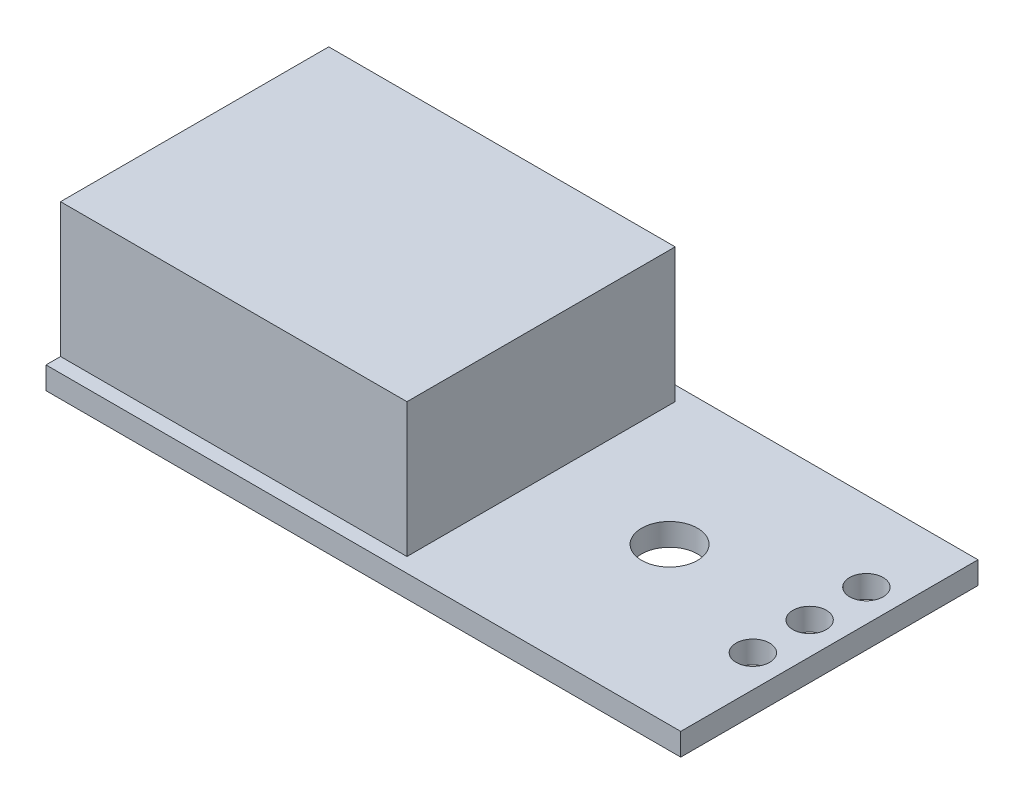
from build123d import *

# Parameters (mm, degrees)
SKETCH_1_W             = 28.4
SKETCH_1_H             = 13.3
EXTRUDE_1_DEPTH        = 1
SKETCH_2_R             = 1.25
CUT_EXTRUDE_1_DEPTH    = 2
EXTRUDE_START          = -1
SKETCH_3_W             = 15.5
SKETCH_3_H             = 12
EXTRUDE_2_DEPTH        = 7
SKETCH_4_R             = 0.75
CUT_EXTRUDE_2_DEPTH    = 2
PATTERN_LINEAR_1_COUNT = 3
PATTERN_LINEAR_1_PITCH = 2.54


with BuildPart() as part:
    # 草图1 → 凸台-拉伸1 (new body)
    with BuildSketch(Plane(origin=(0, 0, 0), x_dir=(1, 0, 0), z_dir=(0, 1, 0))):
        Rectangle(SKETCH_1_W, SKETCH_1_H)
    extrude(amount=EXTRUDE_1_DEPTH)

    # 草图2 → 切除-拉伸1 (cut, through all)
    with BuildSketch(Plane(origin=(0, 1, 0), x_dir=(1, 0, 0), z_dir=(0, 1, 0))):
        with Locations((6.7, 0.35)):
            Circle(SKETCH_2_R)
    extrude(amount=-CUT_EXTRUDE_1_DEPTH, mode=Mode.SUBTRACT)

    # 草图3 → 凸台-拉伸2 (add)
    with BuildSketch(Plane(origin=(0, 1, 0), x_dir=(1, 0, 0), z_dir=(0, 1, 0)).offset(EXTRUDE_START)):
        with Locations((-6.45, 0)):
            Rectangle(SKETCH_3_W, SKETCH_3_H)
    extrude(amount=EXTRUDE_2_DEPTH)

    # 草图4 → 切除-拉伸2 (cut, through all)
    with BuildSketch(Plane(origin=(0, 1, 0), x_dir=(1, 0, 0), z_dir=(0, 1, 0))):
        with Locations((12.765289475, 3.091279596)):
            Circle(SKETCH_4_R)
    cut_extrude_2 = extrude(amount=-CUT_EXTRUDE_2_DEPTH, mode=Mode.SUBTRACT)

    # 阵列(线性)1: 切除-拉伸2 ×3
    with Locations(*[(0, 0, i * PATTERN_LINEAR_1_PITCH) for i in range(1, PATTERN_LINEAR_1_COUNT)]):
        add(cut_extrude_2, mode=Mode.SUBTRACT)


solid = part.part
